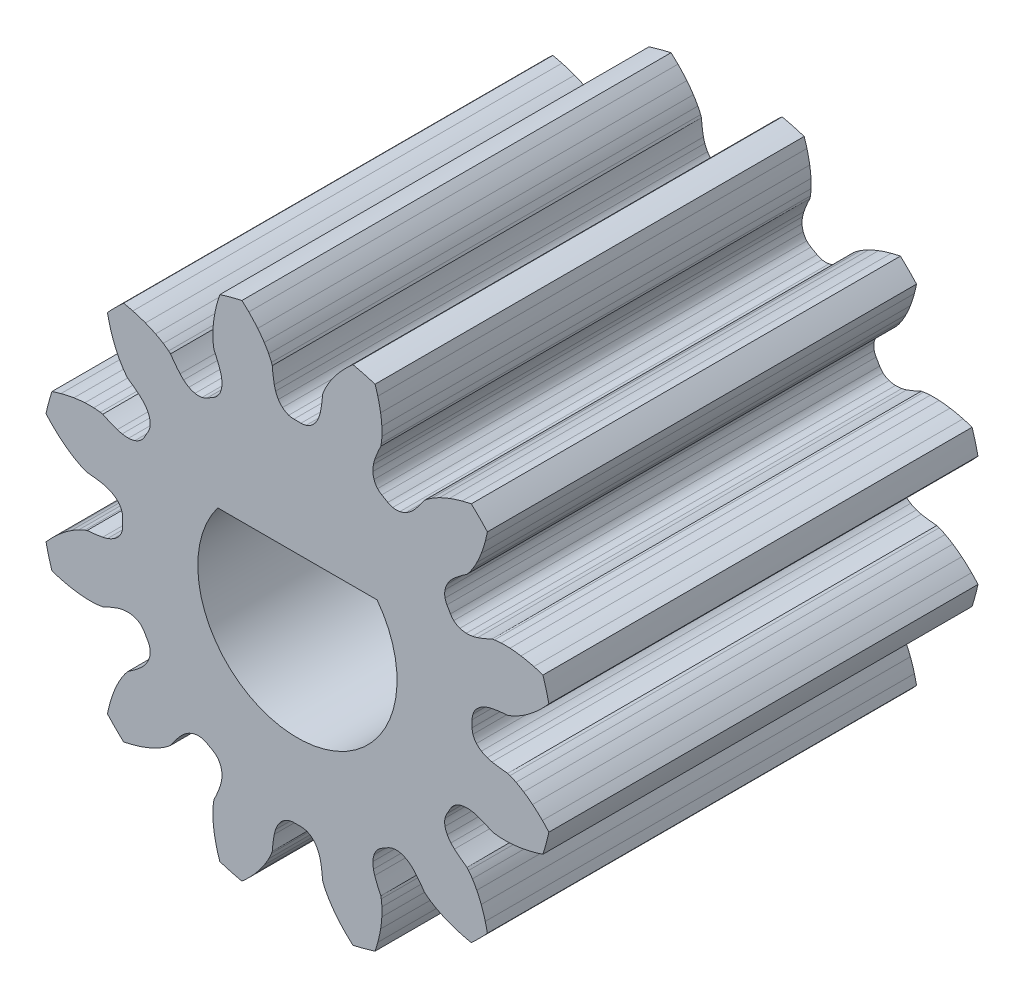
from build123d import *

# Parameters (mm, degrees)
SKETCH_338_R                 = 4.200003307
F_0_6_7_2000MM_P_D_DEPTH     = 3.5
CUT_EXTRUDE_20_DEPTH         = 4.5
PATTERN_CIRCULAR_12_12_COUNT = 12
EXTRUDE3_DEPTH               = 10


with BuildPart() as part:
    # Sketch 338 → 0.6 _ _ 7.2000mm P.D (new body, symmetric)
    with BuildSketch(Plane.XY):
        Circle(SKETCH_338_R)
    extrude(amount=F_0_6_7_2000MM_P_D_DEPTH, both=True)

    # 0.0000mm → Cut-Extrude 20 (cut, symmetric)
    with BuildSketch(Plane.XY):
        with BuildLine():
            Line((-0.423455637, 3.467948485), (-0.409585372, 3.429854642))
            ThreePointArc((-0.409585372, 3.429854642), (-0.397488358, 3.302192649), (-0.377263708, 3.175563719))
            ThreePointArc((-0.377263708, 3.175563719), (-0.367699543, 3.135493511), (-0.355544459, 3.096131744))
            ThreePointArc((-0.355544459, 3.096131744), (-0.335874206, 3.047563013), (-0.311015218, 3.001434157))
            ThreePointArc((-0.311015218, 3.001434157), (-0.280135051, 2.958386087), (-0.243239593, 2.920367063))
            ThreePointArc((-0.243239593, 2.920367063), (-0.195856835, 2.886277876), (-0.14254704, 2.862502593))
            ThreePointArc((-0.14254704, 2.862502593), (-0.100342549, 2.852814302), (-0.057172886, 2.849428724))
            ThreePointArc((-0.057172886, 2.849428724), (0, 2.850002244), (0.057172886, 2.849428724))
            ThreePointArc((0.057172886, 2.849428724), (0.100342549, 2.852814302), (0.14254704, 2.862502593))
            ThreePointArc((0.14254704, 2.862502593), (0.195856835, 2.886277876), (0.243239593, 2.920367063))
            ThreePointArc((0.243239593, 2.920367063), (0.280135051, 2.958386087), (0.311015218, 3.001434157))
            ThreePointArc((0.311015218, 3.001434157), (0.335874206, 3.047563013), (0.355544459, 3.096131744))
            ThreePointArc((0.355544459, 3.096131744), (0.367699543, 3.135493511), (0.377263708, 3.175563719))
            ThreePointArc((0.377263708, 3.175563719), (0.397488358, 3.302192649), (0.409585372, 3.429854642))
            Line((0.409585372, 3.429854642), (0.423455637, 3.467948485))
            ThreePointArc((0.423455637, 3.467948485), (0.444642954, 3.517677071), (0.468361476, 3.566249352))
            ThreePointArc((0.468361476, 3.566249352), (0.503245554, 3.629316478), (0.541332386, 3.690502706))
            ThreePointArc((0.541332386, 3.690502706), (0.592795175, 3.764447025), (0.648000806, 3.835640559))
            ThreePointArc((0.648000806, 3.835640559), (0.718545879, 3.91755934), (0.793220483, 3.99573221))
            ThreePointArc((0.793220483, 3.99573221), (0.884914008, 4.082334738), (0.980951061, 4.164094049))
            ThreePointArc((0.980951061, 4.164094049), (0, 4.278077165), (-0.980951061, 4.164094049))
            ThreePointArc((-0.980951061, 4.164094049), (-0.884914008, 4.082334738), (-0.793220483, 3.99573221))
            ThreePointArc((-0.793220483, 3.99573221), (-0.718545879, 3.91755934), (-0.648000806, 3.835640559))
            ThreePointArc((-0.648000806, 3.835640559), (-0.592795175, 3.764447025), (-0.541332386, 3.690502706))
            ThreePointArc((-0.541332386, 3.690502706), (-0.503245554, 3.629316478), (-0.468361476, 3.566249352))
            ThreePointArc((-0.468361476, 3.566249352), (-0.444642954, 3.517677071), (-0.423455637, 3.467948485))
        make_face()
    cut_extrude_20 = extrude(amount=CUT_EXTRUDE_20_DEPTH, both=True, mode=Mode.SUBTRACT)

    # Pattern Circular 12 _ 12: Cut-Extrude 20 ×12 about axis
    pattern_circular_12_12_axis = Axis((0, 0, 0), (0, 0, 1))
    for i in range(1, PATTERN_CIRCULAR_12_12_COUNT):
        add(cut_extrude_20.rotate(pattern_circular_12_12_axis, i * 360 / PATTERN_CIRCULAR_12_12_COUNT), mode=Mode.SUBTRACT)

    # Sketch3 → Extrude3 (cut)
    with BuildSketch(Plane.XY.offset(3.5)):
        with BuildLine():
            Line((-1.3, 0.975), (1.3, 0.975))
            ThreePointArc((1.3, 0.975), (0, -1.625), (-1.3, 0.975))
        make_face()
    extrude(amount=-EXTRUDE3_DEPTH, mode=Mode.SUBTRACT)


solid = part.part
